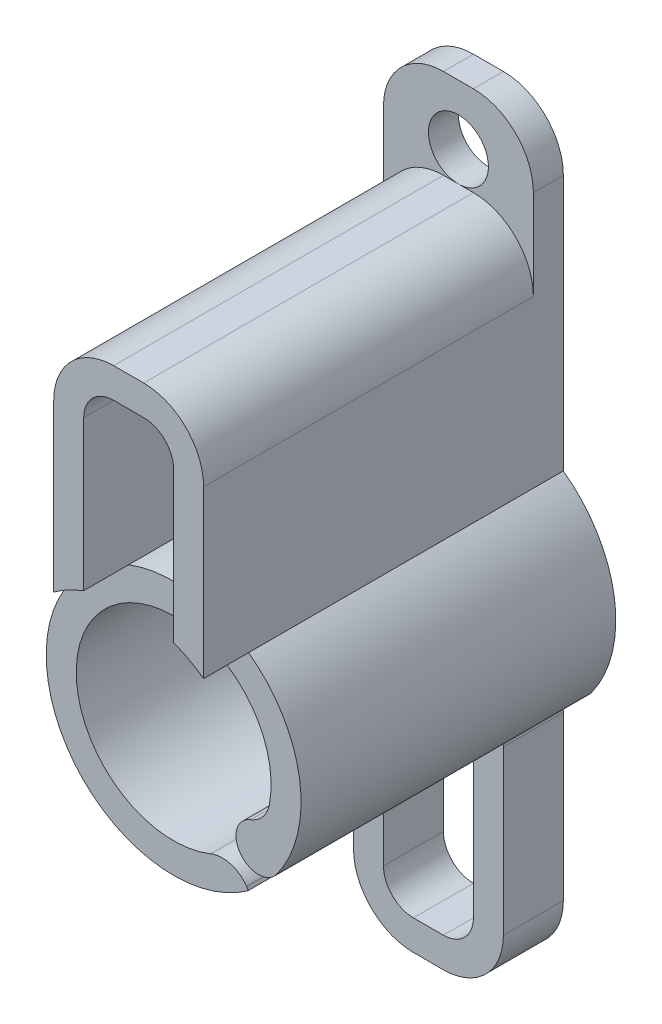
from build123d import *

# Parameters (mm, degrees)
Y_KSEKLIK_EKSTR_ZYON1_DEPTH = 12
KES_EKSTR_ZYON1_DEPTH       = 10
Y_KSEKLIK_EKSTR_ZYON7_DEPTH = 1
IZIM4_R                     = 1
KES_EKSTR_ZYON2_DEPTH       = 11
IZIM6_R                     = 4.25
KES_EKSTR_ZYON3_DEPTH       = 1.5


with BuildPart() as part:
    # Çizim1 → Yükseklik-Ekstrüzyon1 (new body)
    with BuildSketch(Plane.XY):
        with BuildLine():
            ThreePointArc((3.192280857, -0.60978925), (2.975857359, -1.065220637), (2.56471968, -1.357149888))
            ThreePointArc((2.56471968, -1.357149888), (2.234721924, -2.513666231), (3.437313781, -2.499474739))
            ThreePointArc((3.437313781, -2.499474739), (4.19799408, 0.662831579), (2.5, 3.436931771))
            Line((2.5, 3.436931771), (2.5, 8.97649343))
            ThreePointArc((2.5, 8.97649343), (1.914213562, 10.390706993), (0.5, 10.97649343))
            Line((0.5, 10.97649343), (-0.5, 10.97649343))
            ThreePointArc((-0.5, 10.97649343), (-1.914213562, 10.390706993), (-2.5, 8.97649343))
            Line((-2.5, 8.97649343), (-2.5, 3.436931771))
            ThreePointArc((-2.5, 3.436931771), (-4.25, 0), (-2.5, -3.436931771))
            Line((-2.5, -3.436931771), (-2.5, -8.97649343))
            ThreePointArc((-2.5, -8.97649343), (-1.914213562, -10.390706993), (-0.5, -10.97649343))
            Line((-0.5, -10.97649343), (0.5, -10.97649343))
            ThreePointArc((0.5, -10.97649343), (1.914213562, -10.390706993), (2.5, -8.97649343))
            Line((2.5, -8.97649343), (2.5, -3.534499959))
            ThreePointArc((2.5, -3.534499959), (2.485291154, -3.44171549), (2.442606949, -3.35802937))
            Line((2.442606949, -3.35802937), (2.429810536, -3.340437211))
            ThreePointArc((2.429810536, -3.340437211), (1.892940792, -2.966324418), (1.239680541, -3.004278975))
            ThreePointArc((1.239680541, -3.004278975), (-2.518723033, 2.053907077), (3.192280857, -0.60978925))
        make_face()
        with BuildLine():
            Line((1.5, 3.97649343), (1.5, 8.97649343))
            ThreePointArc((1.5, 8.97649343), (1.207106781, 9.683600211), (0.5, 9.97649343))
            Line((0.5, 9.97649343), (-0.5, 9.97649343))
            ThreePointArc((-0.5, 9.97649343), (-1.207106781, 9.683600211), (-1.5, 8.97649343))
            Line((-1.5, 8.97649343), (-1.5, 3.97649343))
            ThreePointArc((-1.5, 3.97649343), (0, 4.25), (1.5, 3.97649343))
        make_face(mode=Mode.SUBTRACT)
        with BuildLine():
            ThreePointArc((0.5, -9.97649343), (1.207106781, -9.683600211), (1.5, -8.97649343))
            Line((1.5, -8.97649343), (1.5, -3.97649343))
            ThreePointArc((1.5, -3.97649343), (0, -4.25), (-1.5, -3.97649343))
            Line((-1.5, -3.97649343), (-1.5, -8.97649343))
            ThreePointArc((-1.5, -8.97649343), (-1.207106781, -9.683600211), (-0.5, -9.97649343))
            Line((-0.5, -9.97649343), (0.5, -9.97649343))
        make_face(mode=Mode.SUBTRACT)
    extrude(amount=Y_KSEKLIK_EKSTR_ZYON1_DEPTH)

    # Çizim2 → Kes-Ekstrüzyon1 (cut)
    with BuildSketch(Plane.XY.offset(12)):
        with BuildLine():
            Line((-2.5, -3.436931771), (-2.5, -10.97649343))
            Line((-2.5, -10.97649343), (2.5, -10.97649343))
            Line((2.5, -10.97649343), (2.5, -3.436931771))
            ThreePointArc((2.5, -3.436931771), (0, -4.25), (-2.5, -3.436931771))
        make_face()
    extrude(amount=-KES_EKSTR_ZYON1_DEPTH, mode=Mode.SUBTRACT)

    # Çizim3 → Yükseklik-Ekstrüzyon7 (add)
    with BuildSketch(Plane(origin=(0, 0, 0), x_dir=(-1, 0, 0), z_dir=(0, 0, -1))):
        with BuildLine():
            ThreePointArc((-2.5, 11.97649343), (-1.914213562, 13.390706993), (-0.5, 13.97649343))
            Line((-0.5, 13.97649343), (0.5, 13.97649343))
            ThreePointArc((0.5, 13.97649343), (1.914213562, 13.390706993), (2.5, 11.97649343))
            Line((2.5, 11.97649343), (2.5, 8.97649343))
            ThreePointArc((2.5, 8.97649343), (1.914213562, 10.390706993), (0.5, 10.97649343))
            Line((0.5, 10.97649343), (-0.5, 10.97649343))
            ThreePointArc((-0.5, 10.97649343), (-1.914213562, 10.390706993), (-2.5, 8.97649343))
            Line((-2.5, 8.97649343), (-2.5, 11.97649343))
        make_face()
    extrude(amount=-Y_KSEKLIK_EKSTR_ZYON7_DEPTH)

    # Çizim4 → Kes-Ekstrüzyon2 (cut)
    with BuildSketch(Plane(origin=(0, 0, 0), x_dir=(-1, 0, 0), z_dir=(0, 0, -1))):
        with Locations((0, 11.97649343)):
            Circle(IZIM4_R)
    extrude(amount=-KES_EKSTR_ZYON2_DEPTH, mode=Mode.SUBTRACT)

    # Çizim6 → Kes-Ekstrüzyon3 (cut)
    with BuildSketch(Plane.XY.offset(12)):
        Circle(IZIM6_R)
    extrude(amount=-KES_EKSTR_ZYON3_DEPTH, mode=Mode.SUBTRACT)


solid = part.part
